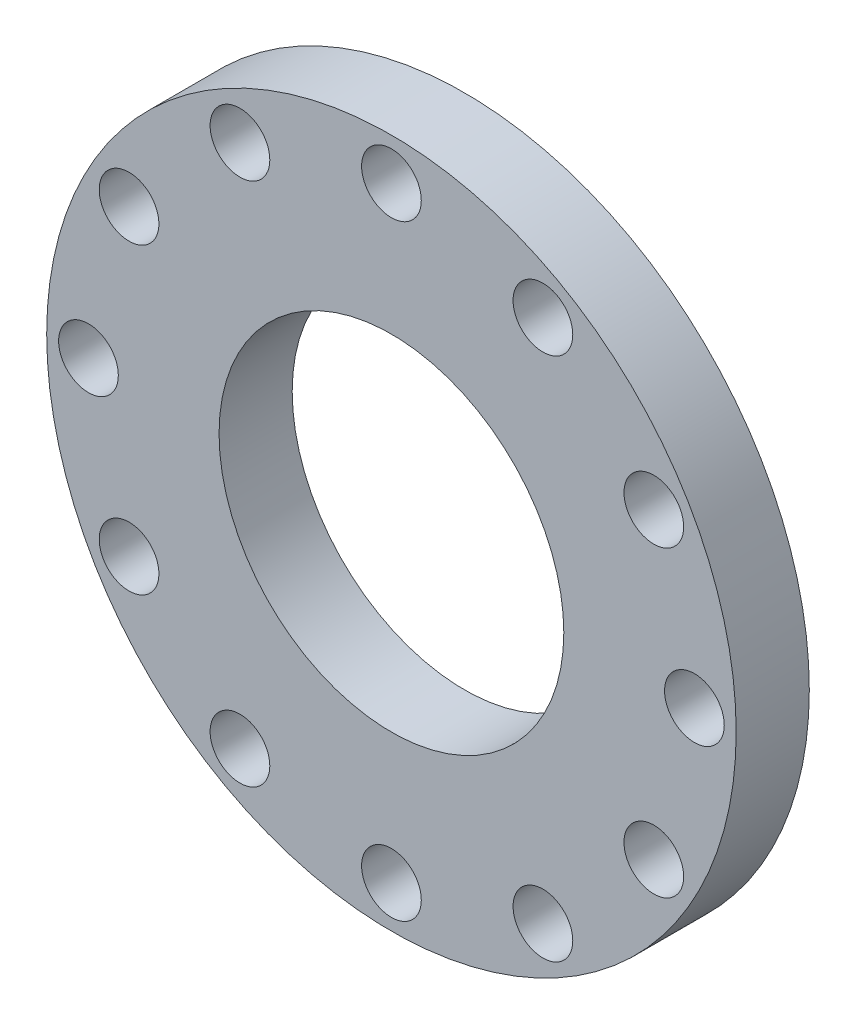
from build123d import *

# Parameters (mm, degrees)
SKETCH1_R           = 330
SKETCH1_R_2         = 165
BOSS_EXTRUDE1_DEPTH = 70
SKETCH2_R           = 28.575
CUT_EXTRUDE1_DEPTH  = 131


with BuildPart() as part:
    # Sketch1 → Boss-Extrude1 (new body)
    with BuildSketch(Plane.XY):
        Circle(SKETCH1_R)
        Circle(SKETCH1_R_2, mode=Mode.SUBTRACT)
    extrude(amount=BOSS_EXTRUDE1_DEPTH)

    # Sketch2 → Cut-Extrude1 (cut)
    with BuildSketch(Plane.XY):
        with Locations((0, 290)):
            Circle(SKETCH2_R)
        with Locations((145, 251.147367097)):
            Circle(SKETCH2_R)
        with Locations((251.147367097, 145)):
            Circle(SKETCH2_R)
        with Locations((290, 0)):
            Circle(SKETCH2_R)
        with Locations((251.147367098, -145)):
            Circle(SKETCH2_R)
        with Locations((145, -251.147367097)):
            Circle(SKETCH2_R)
        with Locations((0, -290)):
            Circle(SKETCH2_R)
        with Locations((-145, -251.147367097)):
            Circle(SKETCH2_R)
        with Locations((-251.147367097, -145)):
            Circle(SKETCH2_R)
        with Locations((-290, 0)):
            Circle(SKETCH2_R)
        with Locations((-251.147367097, 145)):
            Circle(SKETCH2_R)
        with Locations((-145, 251.147367097)):
            Circle(SKETCH2_R)
    extrude(amount=CUT_EXTRUDE1_DEPTH, mode=Mode.SUBTRACT)


solid = part.part
